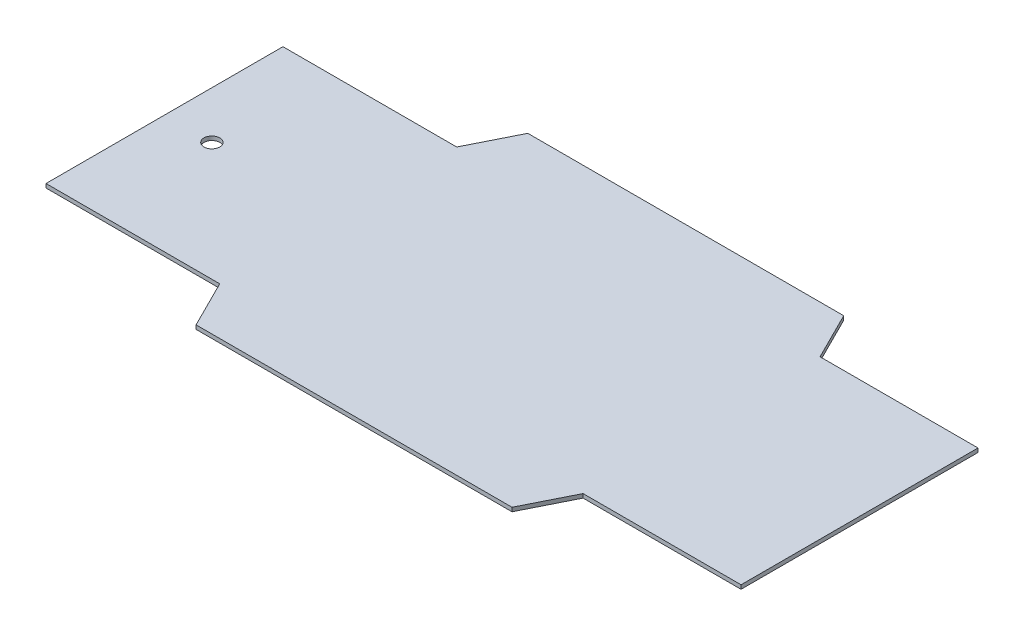
from build123d import *

# Parameters (mm, degrees)
BOSS_EXTRUDE1_DEPTH = 1.5875
SKETCH8_R           = 6.35
CUT_EXTRUDE1_DEPTH  = 5.08


with BuildPart() as part:
    # Sketch3 → Boss-Extrude1 (new body, symmetric)
    with BuildSketch(Plane(origin=(0, 0, 0), x_dir=(1, 0, 0), z_dir=(0, 1, 0))):
        Polygon((-279.4, 95.25), (-139.7, 95.25), (-120.65, 133.35), (133.35, 133.35), (152.4, 95.25), (279.4, 95.25), (279.4, -95.25), (152.4, -95.25), (133.35, -133.35), (-120.65, -133.35), (-139.7, -95.25), (-279.4, -95.25), align=None)
    extrude(amount=BOSS_EXTRUDE1_DEPTH, both=True)

    # Sketch8 → Cut-Extrude1 (cut)
    with BuildSketch(Plane(origin=(0, 1.5875, 0), x_dir=(1, 0, 0), z_dir=(0, 1, 0))):
        with Locations((-241.3, 0)):
            Circle(SKETCH8_R)
    extrude(amount=-CUT_EXTRUDE1_DEPTH, mode=Mode.SUBTRACT)


solid = part.part
